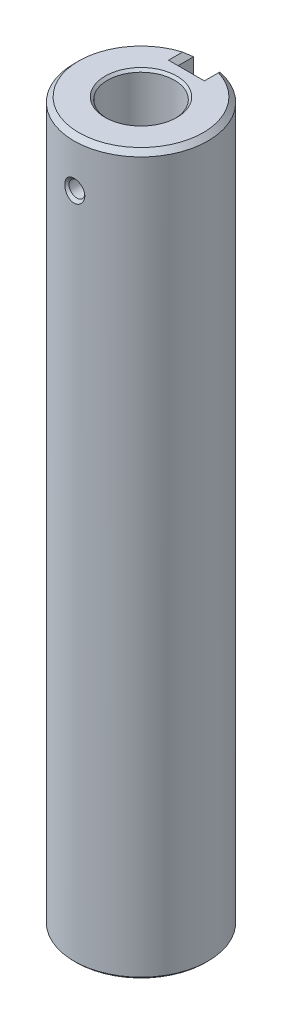
from build123d import *

# Parameters (mm, degrees)
ESQUISSE1_R                               = 14
BOSS_EXTRU_1_DEPTH                        = 150
CHANFREIN1_SIZE                           = 1
DIAM_TRE_DU_PER_AGE_14_0_14_1_D           = 14
DIAM_TRE_DU_PER_AGE_14_0_14_1_DEPTH       = 35
DIAM_TRE_DU_PER_AGE_14_0_14_1_CSINK_D     = 15
DIAM_TRE_DU_PER_AGE_14_0_14_1_CSINK_ANGLE = 90
DIAM_TRE_DU_PER_AGE_14_0_14_1_TIP         = 4.206024333
CHANFREIN2_SIZE                           = 0.5
TROU_TARAUD_M8X1_01_D                     = 7
TROU_TARAUD_M8X1_01_DEPTH                 = 25
TROU_TARAUD_M8X1_01_TIP                   = 2.103012167
ENL_V_MAT_EXTRU_1_REACH                   = 152
ESQUISSE13_W                              = 5.5
ESQUISSE13_H                              = 4.102839415
CHANFREIN3_SIZE                           = 1
CHANFREIN4_SIZE                           = 1


with BuildPart() as part:
    # Esquisse1 → Boss.-Extru.1 (new body)
    with BuildSketch(Plane(origin=(0, 0, 0), x_dir=(1, 0, 0), z_dir=(0, 1, 0))):
        with Locations(Location((0, 0, 0), (0, 0, 270))):  # turned: the seam where the file's is
            Circle(ESQUISSE1_R)
    extrude(amount=BOSS_EXTRU_1_DEPTH)

    # Chanfrein1
    chanfrein1_edges = [part.edges().sort_by_distance(p)[0] for p in [
        (0, 150, -14),
    ]]
    chamfer(chanfrein1_edges, length=CHANFREIN1_SIZE)

    # Diamètre du perçage Ø14.0 (14)1
    with Locations(Plane(origin=(0, 150, 0), x_dir=(-1, 0, 0), z_dir=(0, 1, 0))):
        with Locations((0, 0)):
            CounterSinkHole(DIAM_TRE_DU_PER_AGE_14_0_14_1_D / 2, DIAM_TRE_DU_PER_AGE_14_0_14_1_CSINK_D / 2, depth=DIAM_TRE_DU_PER_AGE_14_0_14_1_DEPTH, counter_sink_angle=DIAM_TRE_DU_PER_AGE_14_0_14_1_CSINK_ANGLE)
            with Locations((0, 0, -(DIAM_TRE_DU_PER_AGE_14_0_14_1_DEPTH + DIAM_TRE_DU_PER_AGE_14_0_14_1_TIP / 2))):  # 118° drill point
                Cone(0, DIAM_TRE_DU_PER_AGE_14_0_14_1_D / 2, DIAM_TRE_DU_PER_AGE_14_0_14_1_TIP, mode=Mode.SUBTRACT)

    # Chanfrein2
    chanfrein2_edges = [part.edges().sort_by_distance(p)[0] for p in [
        (0, 0, -14),
    ]]
    chamfer(chanfrein2_edges, length=CHANFREIN2_SIZE)

    # Trou taraudé M8x1.01
    with Locations(Plane.XZ):
        with Locations((0, 0)):
            Hole(TROU_TARAUD_M8X1_01_D / 2, depth=TROU_TARAUD_M8X1_01_DEPTH)
            with Locations((0, 0, -(TROU_TARAUD_M8X1_01_DEPTH + TROU_TARAUD_M8X1_01_TIP / 2))):  # 118° drill point
                Cone(0, TROU_TARAUD_M8X1_01_D / 2, TROU_TARAUD_M8X1_01_TIP, mode=Mode.SUBTRACT)

    # Esquisse11 → Trou taraudé M42 (revolve, cut)
    with BuildSketch(Plane(origin=(0, 140, 0), x_dir=(0, 1, 0), z_dir=(1, 0, 0))):
        Polygon((0, 0), (0, 14), (2.25, 14), (1.65, 13.4), (1.65, 0), align=None)
    revolve(axis=Axis((0, 140, -6.35), (0, 0, 1)), mode=Mode.SUBTRACT)

    # Esquisse13 → Enlèv. mat.-Extru.1 (cut, up to next)
    with BuildSketch(Plane(origin=(0, 150, 0), x_dir=(-1, 0, 0), z_dir=(0, 1, 0)), mode=Mode.PRIVATE) as enl_v_mat_extru_1_sk1:
        with Locations((0, -12.551419707)):
            Rectangle(ESQUISSE13_W, ESQUISSE13_H)
    enl_v_mat_extru_1_tool1 = extrude(enl_v_mat_extru_1_sk1.sketch, amount=-ENL_V_MAT_EXTRU_1_REACH, mode=Mode.PRIVATE) & part.part
    add(enl_v_mat_extru_1_tool1.solids().sort_by_distance((0, 150, -12.55142))[0], mode=Mode.SUBTRACT)

    # Chanfrein3
    chanfrein3_edges = [part.edges().sort_by_distance(p)[0] for p in [
        (2.75, 0, -11.858469944),
        (-2.75, 0, -11.858469944),
        (0, 0, -10.5),
    ]]
    chamfer(chanfrein3_edges, length=CHANFREIN3_SIZE)

    # Chanfrein4
    chanfrein4_edges = [part.edges().sort_by_distance(p)[0] for p in [
        (2.75, 150, -11.60290288),
        (-2.75, 150, -11.60290288),
        (0, 150, -10.5),
    ]]
    chamfer(chanfrein4_edges, length=CHANFREIN4_SIZE)


solid = part.part
